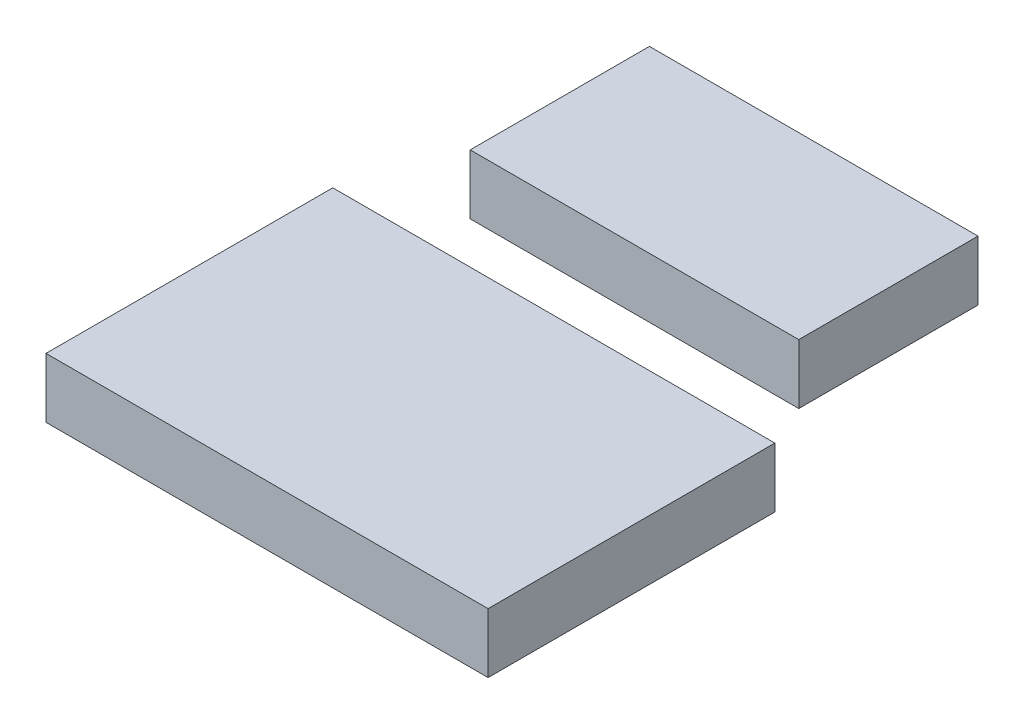
from build123d import *

# Parameters (mm, degrees)
BOSS_EXTRUDE1_DEPTH   = 10
SKETCH1_W             = 55
SKETCH1_H             = 30
BOSS_EXTRUDE1_2_DEPTH = 10


with BuildPart() as part:
    # Sketch1 → Boss-Extrude1 (new body)
    with BuildSketch(Plane(origin=(0, 0, 0), x_dir=(1, 0, 0), z_dir=(0, 1, 0))):
        Polygon((24, 0.5), (-31, 0.5), (-37, 0.5), (-37, -47.5), (37, -47.5), (37, 0.5), align=None)
    extrude(amount=BOSS_EXTRUDE1_DEPTH)


with BuildPart() as body_2:
    # Sketch1 → Boss-Extrude1 2 (new body)
    with BuildSketch(Plane(origin=(0, 0, 0), x_dir=(1, 0, 0), z_dir=(0, 1, 0))):
        with Locations((-3.5, 32.5)):
            Rectangle(SKETCH1_W, SKETCH1_H)
    extrude(amount=BOSS_EXTRUDE1_2_DEPTH)


solid = Compound([part.part, body_2.part])
